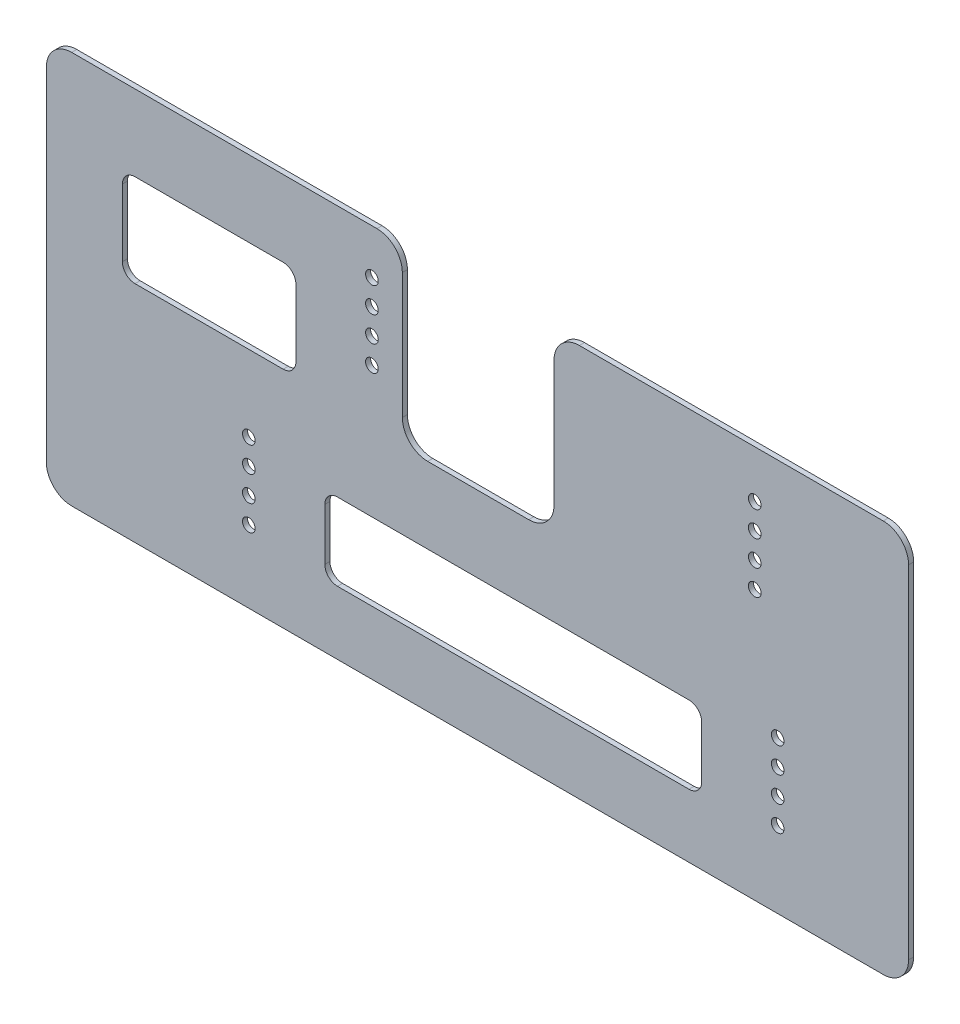
from build123d import *

# Parameters (mm, degrees)
SKETCH1_W           = 340.2
SKETCH1_H           = 155
BOSS_EXTRUDE1_DEPTH = 2
SKETCH2_R           = 2.5
CUT_EXTRUDE1_DEPTH  = 3
LPATTERN1_COUNT     = 4
LPATTERN1_PITCH     = 10
SKETCH3_W           = 59.862571915
SKETCH3_H           = 20.5
CUT_EXTRUDE2_DEPTH  = 3
LPATTERN2_COUNT     = 5
LPATTERN2_PITCH     = 10
SKETCH4_W           = 59.862571915
SKETCH4_H           = 9.012650354
CUT_EXTRUDE3_DEPTH  = 3
FILLET1_R           = 10
FILLET2_R           = 10
CUT_EXTRUDE4_DEPTH  = 3


with BuildPart() as part:
    # Sketch1 → Boss-Extrude1 (new body)
    with BuildSketch(Plane.XY):
        with Locations((440, -1022.5)):
            Rectangle(SKETCH1_W, SKETCH1_H)
    extrude(amount=BOSS_EXTRUDE1_DEPTH)

    # Sketch2 → Cut-Extrude1 (cut, through all)
    with BuildSketch(Plane.XY.offset(2)):
        with Locations((558.449514061, -1039.939996933)):
            Circle(SKETCH2_R)
        with Locations((349.784616085, -1041.525975933)):
            Circle(SKETCH2_R)
        with Locations((398.354490085, -962.715267)):
            Circle(SKETCH2_R)
        with Locations((549.405587829, -963.765953)):
            Circle(SKETCH2_R)
    cut_extrude1 = extrude(amount=-CUT_EXTRUDE1_DEPTH, mode=Mode.SUBTRACT)

    # LPattern1: Cut-Extrude1 ×4
    with Locations(*[(0, -i * LPATTERN1_PITCH, 0) for i in range(1, LPATTERN1_COUNT)]):
        add(cut_extrude1, mode=Mode.SUBTRACT)

    # Sketch3 → Cut-Extrude2 (cut, through all)
    with BuildSketch(Plane.XY.offset(2)):
        with Locations((440.285320332, -964.262650354)):
            Rectangle(SKETCH3_W, SKETCH3_H)
    cut_extrude2 = extrude(amount=-CUT_EXTRUDE2_DEPTH, mode=Mode.SUBTRACT)

    # LPattern2: Cut-Extrude2 ×5
    with Locations(*[(0, -i * LPATTERN2_PITCH, 0) for i in range(1, LPATTERN2_COUNT)]):
        add(cut_extrude2, mode=Mode.SUBTRACT)

    # Sketch4 → Cut-Extrude3 (cut, through all)
    with BuildSketch(Plane.XY.offset(2)):
        with Locations((440.285320332, -949.506325177)):
            Rectangle(SKETCH4_W, SKETCH4_H)
    extrude(amount=-CUT_EXTRUDE3_DEPTH, mode=Mode.SUBTRACT)

    # Fillet1
    fillet1_edges = [part.edges().sort_by_distance(p)[0] for p in [
        (470.216606289, -945, 1),
        (410.354034374, -945, 1),
        (410.354034374, -1014.512650354, 1),
        (470.216606289, -1014.512650354, 1),
    ]]
    fillet(fillet1_edges, radius=FILLET1_R)

    # Fillet2
    fillet2_edges = [part.edges().sort_by_distance(p)[0] for p in [
        (610.1, -1100, 1),
        (269.9, -1100, 1),
        (269.9, -945, 1),
        (610.1, -945, 1),
    ]]
    fillet(fillet2_edges, radius=FILLET2_R)

    # Sketch5 → Cut-Extrude4 (cut, through all)
    with BuildSketch(Plane.XY.offset(2)):
        with BuildLine():
            Line((523.449514061, -1075), (384.784616085, -1075))
            ThreePointArc((384.784616085, -1075), (381.249082179, -1073.535533906), (379.784616085, -1070))
            Line((379.784616085, -1070), (379.784616085, -1049.512650354))
            ThreePointArc((379.784616085, -1049.512650354), (381.249082179, -1045.977116448), (384.784616085, -1044.512650354))
            Line((384.784616085, -1044.512650354), (523.449514061, -1044.512650354))
            ThreePointArc((523.449514061, -1044.512650354), (526.985047967, -1045.977116448), (528.449514061, -1049.512650354))
            Line((528.449514061, -1049.512650354), (528.449514061, -1070))
            ThreePointArc((528.449514061, -1070), (526.985047967, -1073.535533906), (523.449514061, -1075))
        make_face()
        with BuildLine():
            Line((363.354490085, -1011.525975933), (304.9, -1011.525975933))
            ThreePointArc((304.9, -1011.525975933), (301.364466094, -1010.061509839), (299.9, -1006.525975933))
            Line((299.9, -1006.525975933), (299.9, -980))
            ThreePointArc((299.9, -980), (301.364466094, -976.464466094), (304.9, -975))
            Line((304.9, -975), (363.354490085, -975))
            ThreePointArc((363.354490085, -975), (366.890023991, -976.464466094), (368.354490085, -980))
            Line((368.354490085, -980), (368.354490085, -1006.525975933))
            ThreePointArc((368.354490085, -1006.525975933), (366.890023991, -1010.061509839), (363.354490085, -1011.525975933))
        make_face()
    extrude(amount=-CUT_EXTRUDE4_DEPTH, mode=Mode.SUBTRACT)


solid = part.part
